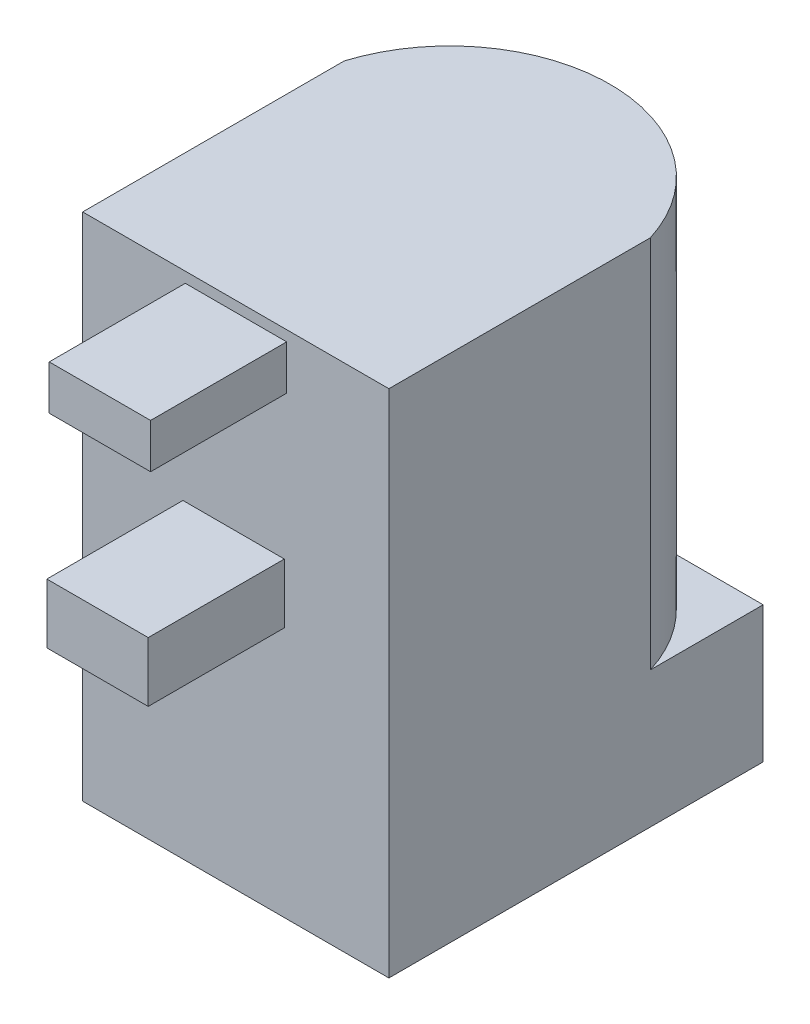
from build123d import *

# Parameters (mm, degrees)
SKETCH1_W           = 9
SKETCH1_H           = 11
BOSS_EXTRUDE1_DEPTH = 15
CUT_EXTRUDE1_DEPTH  = 11
SKETCH3_R           = 3.15
CUT_EXTRUDE2_DEPTH  = 11
SKETCH4_W           = 2.979879399
SKETCH4_H           = 1.306685084
SKETCH4_W_2         = 2.979879398
SKETCH4_H_2         = 1.752870235
BOSS_EXTRUDE2_DEPTH = 4


with BuildPart() as part:
    # Sketch1 → Boss-Extrude1 (new body)
    with BuildSketch(Plane(origin=(0, 0, 0), x_dir=(1, 0, 0), z_dir=(0, 1, 0))):
        with Locations((0.651810585, 0.165738162)):
            Rectangle(SKETCH1_W, SKETCH1_H)
    extrude(amount=BOSS_EXTRUDE1_DEPTH)

    # Sketch2 → Cut-Extrude1 (cut)
    with BuildSketch(Plane(origin=(0, 15, 0), x_dir=(1, 0, 0), z_dir=(0, 1, 0))):
        with BuildLine():
            Line((-3.848189415, 2.350983054), (-6.541968857, 7.081862959))
            Line((-6.541968857, 7.081862959), (7.054694978, 6.829449645))
            Line((7.054694978, 6.829449645), (5.151810585, 2.350983054))
            ThreePointArc((5.151810585, 2.350983054), (0.651810585, 5.665738162), (-3.848189415, 2.350983054))
        make_face()
    extrude(amount=-CUT_EXTRUDE1_DEPTH, mode=Mode.SUBTRACT)

    # Sketch3 → Cut-Extrude2 (cut)
    with BuildSketch(Plane.XZ):
        with Locations((0.651810585, -0.165738162)):
            Circle(SKETCH3_R)
    extrude(amount=-CUT_EXTRUDE2_DEPTH, mode=Mode.SUBTRACT)

    # Sketch4 → Boss-Extrude2 (add)
    with BuildSketch(Plane.XY.offset(5.334261838)):
        with Locations((0.657536683, 14.037179674)):
            Rectangle(SKETCH4_W, SKETCH4_H)
        with Locations((0.588068697, 8.251967659)):
            Rectangle(SKETCH4_W_2, SKETCH4_H_2)
    extrude(amount=BOSS_EXTRUDE2_DEPTH)


solid = part.part
